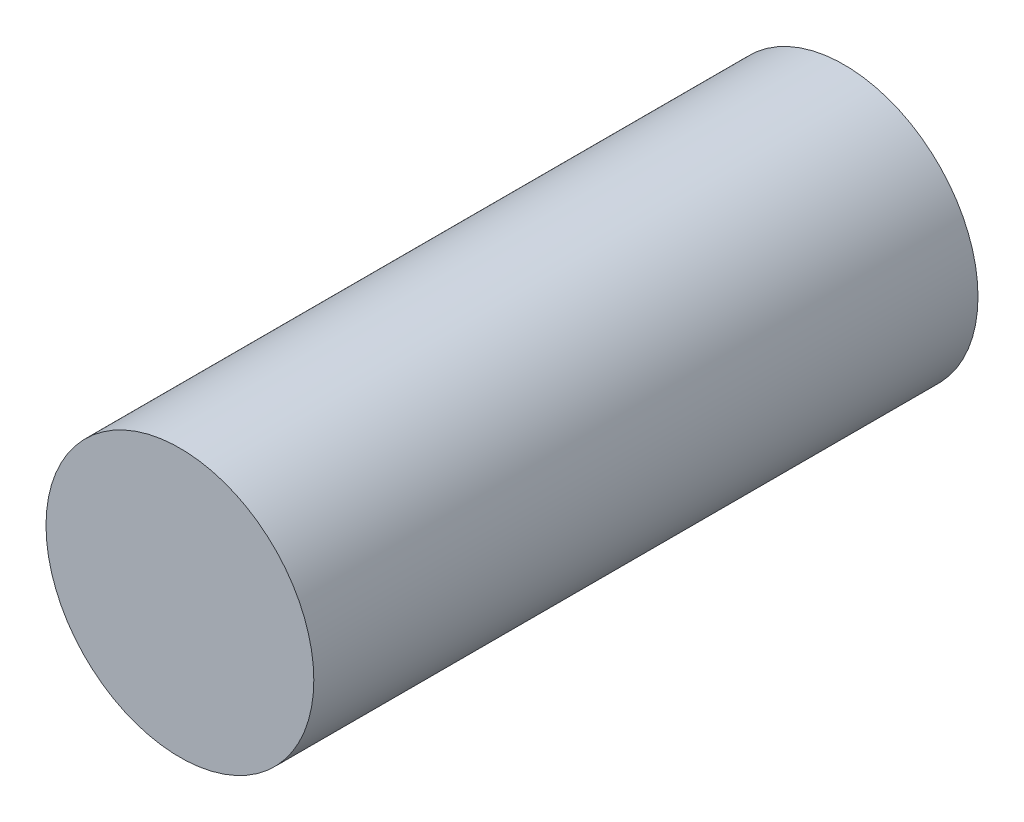
from build123d import *

# Parameters (mm, degrees)
EXTRUDE_START   = -11.9
SKETCH_1_R      = 2.5
EXTRUDE_1_DEPTH = 12.4


with BuildPart() as part:
    # Эскиз1 → Бобышка-Вытянуть1 (new body)
    with BuildSketch(Plane.XY.offset(EXTRUDE_START)):
        Circle(SKETCH_1_R)
    extrude(amount=EXTRUDE_1_DEPTH)


solid = part.part
